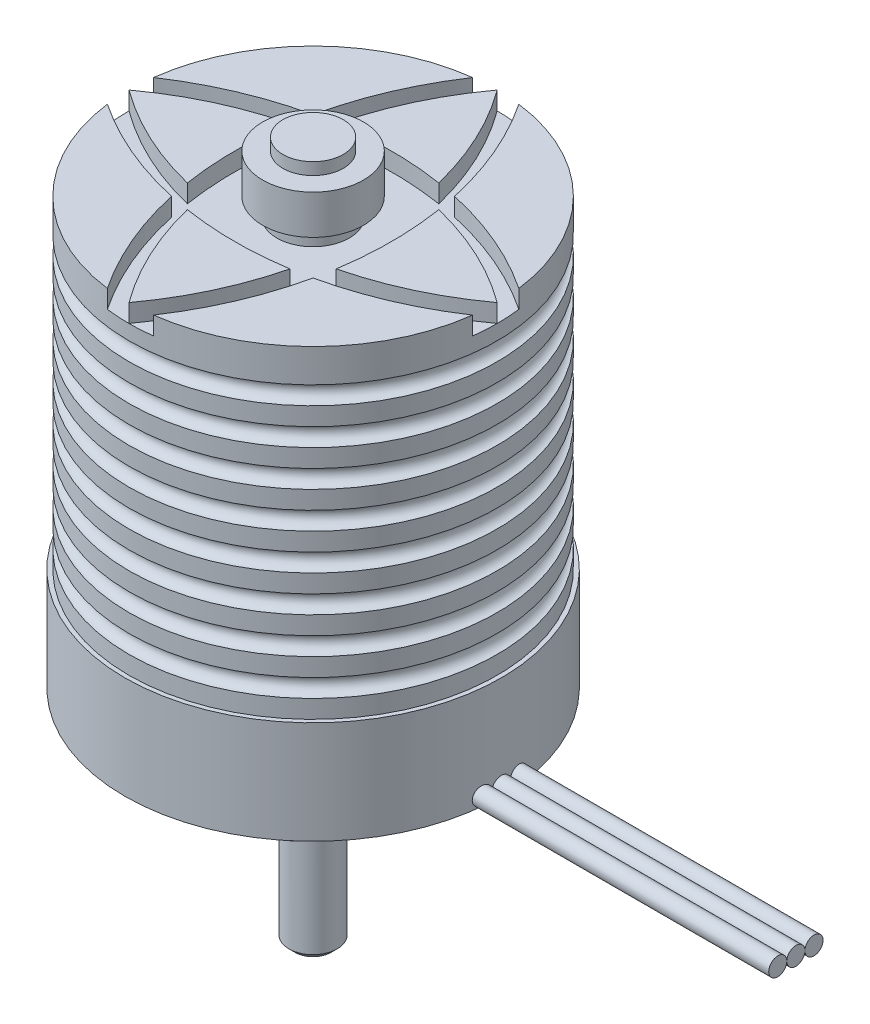
from build123d import *

# Parameters (mm, degrees)
SKETCH1_R                            = 30.5
BOSS_EXTRUDE1_DEPTH                  = 53.5
SKETCH3_R                            = 31.2
BOSS_EXTRUDE3_DEPTH                  = 17
BOSS_EXTRUDE2_START                  = 53.5
SKETCH2_R                            = 4
BOSS_EXTRUDE2_DEPTH                  = 107
LPATTERN3_COUNT                      = 8
LPATTERN3_PITCH                      = 6
SKETCH6_W                            = 1.65
SKETCH6_H                            = 17
TAP_DRILL_FOR_M4X0_7_TAP1_AT_2_COUNT = 2
TAP_DRILL_FOR_M4X0_7_TAP1_AT_2_PITCH = 44
TAP_DRILL_FOR_M4X0_7_TAP1_AT_3_COUNT = 2
TAP_DRILL_FOR_M4X0_7_TAP1_AT_3_PITCH = 31.112698372
TAP_DRILL_FOR_M4X0_7_TAP1_AT_4_COUNT = 2
TAP_DRILL_FOR_M4X0_7_TAP1_AT_4_PITCH = 31.112698372
CIRPATTERN1_COUNT                    = 2
CIRPATTERN1_ANGLE                    = 15
CIRPATTERN1_COPY_1_SKETCH_W          = 1.65
CIRPATTERN1_COPY_1_SKETCH_H          = 17
CIRPATTERN1_COPY_2_SKETCH_W          = 1.65
CIRPATTERN1_COPY_2_SKETCH_H          = 17
CIRPATTERN1_COPY_3_SKETCH_W          = 1.65
CIRPATTERN1_COPY_3_SKETCH_H          = 17
SKETCH7_R                            = 4
CUT_EXTRUDE1_DEPTH                   = 116.74057197
CUT_EXTRUDE_THIN1_START              = -3
CUT_EXTRUDE_THIN1_DEPTH              = 119.74057197
CIRPATTERN2_COUNT                    = 4
SKETCH9_R                            = 6
CUT_EXTRUDE2_DEPTH                   = 3
CUT_EXTRUDE3_DEPTH                   = 1.5
BOSS_EXTRUDE5_REACH                  = 151.348
BOSS_EXTRUDE5_END_RADIUS             = 31.2
BOSS_EXTRUDE5_START                  = 80
SKETCH11_R                           = 1.5
CHAMFER1_SIZE                        = 1


with BuildPart() as part:
    # Sketch1 → Boss-Extrude1 (new body)
    with BuildSketch(Plane(origin=(0, 0, 0), x_dir=(1, 0, 0), z_dir=(0, 1, 0))):
        with Locations(Location((0, 0, 0), (0, 0, 270))):
            Circle(SKETCH1_R)
    extrude(amount=BOSS_EXTRUDE1_DEPTH)

    # Sketch4 → Cut-Revolve1 (revolve, cut)
    with BuildSketch(Plane.XY, mode=Mode.PRIVATE) as cut_revolve1_sk:
        with BuildLine():
            Line((30.5, 6), (30.5, 3))
            ThreePointArc((30.5, 3), (29, 4.5), (30.5, 6))
        make_face()
    cut_revolve1 = revolve(cut_revolve1_sk.sketch.rotate(Axis((0, 0, 0), (0, 1, 0)), 90), axis=Axis((0, 0, 0), (0, 1, 0)), mode=Mode.SUBTRACT)

    # LPattern3: Cut-Revolve1 ×8
    with Locations(*[(0, i * LPATTERN3_PITCH, 0) for i in range(1, LPATTERN3_COUNT)]):
        add(cut_revolve1, mode=Mode.SUBTRACT)


with BuildPart() as body_2:
    # Sketch3 → Boss-Extrude3 (new body)
    with BuildSketch(Plane.XZ):
        with Locations(Location((0, 0, 0), (0, 0, 90))):
            Circle(SKETCH3_R)
    extrude(amount=BOSS_EXTRUDE3_DEPTH)

    # Sketch6 → Tap Drill for M4x0.7 Tap1 (revolve, cut)
    with BuildSketch(Plane(origin=(15.556349186, -17, 15.556349186), x_dir=(0, 0, -1), z_dir=(1, 0, 0))):
        with Locations((0.825, 8.5)):
            Rectangle(SKETCH6_W, SKETCH6_H)
    tap_drill_for_m4x0_7_tap1 = revolve(axis=Axis((15.556349186, -23.35, 15.556349186), (0, 1, 0)), mode=Mode.SUBTRACT)

    # Tap Drill for M4x0.7 Tap1 at 2: Tap Drill for M4x0.7 Tap1 ×2
    with Locations(*[Vector(-0.7071067811865474, 0, -0.7071067811865477) * (i * TAP_DRILL_FOR_M4X0_7_TAP1_AT_2_PITCH) for i in range(1, TAP_DRILL_FOR_M4X0_7_TAP1_AT_2_COUNT)]):
        add(tap_drill_for_m4x0_7_tap1, mode=Mode.SUBTRACT)

    # Tap Drill for M4x0.7 Tap1 at 3: Tap Drill for M4x0.7 Tap1 ×2
    with Locations(*[(-i * TAP_DRILL_FOR_M4X0_7_TAP1_AT_3_PITCH, 0, 0) for i in range(1, TAP_DRILL_FOR_M4X0_7_TAP1_AT_3_COUNT)]):
        add(tap_drill_for_m4x0_7_tap1, mode=Mode.SUBTRACT)

    # Tap Drill for M4x0.7 Tap1 at 4: Tap Drill for M4x0.7 Tap1 ×2
    with Locations(*[(0, 0, -i * TAP_DRILL_FOR_M4X0_7_TAP1_AT_4_PITCH) for i in range(1, TAP_DRILL_FOR_M4X0_7_TAP1_AT_4_COUNT)]):
        add(tap_drill_for_m4x0_7_tap1, mode=Mode.SUBTRACT)

    # CirPattern1: Tap Drill for M4x0.7 Tap1 ×2 about axis
    cirpattern1_axis = Axis((0, 0, 0), (0, 1, 0))
    for i in range(1, CIRPATTERN1_COUNT):
        add(tap_drill_for_m4x0_7_tap1.rotate(cirpattern1_axis, i * CIRPATTERN1_ANGLE / (CIRPATTERN1_COUNT - 1)), mode=Mode.SUBTRACT)

    # CirPattern1 copy 1 sketch → CirPattern1 copy 1 (revolve, cut)
    with BuildSketch(Plane(origin=(-19.052558883, -17, -11), x_dir=(-0.2588190451025214, 0, -0.9659258262890681), z_dir=(0.9659258262890681, 0, -0.2588190451025214))):
        with Locations((0.825, 8.5)):
            Rectangle(CIRPATTERN1_COPY_1_SKETCH_W, CIRPATTERN1_COPY_1_SKETCH_H)
    revolve(axis=Axis((-19.052558883, -23.35, -11), (0, 1, 0)), mode=Mode.SUBTRACT)

    # CirPattern1 copy 2 sketch → CirPattern1 copy 2 (revolve, cut)
    with BuildSketch(Plane(origin=(-11, -17, 19.052558883), x_dir=(-0.2588190451025214, 0, -0.9659258262890681), z_dir=(0.9659258262890681, 0, -0.2588190451025214))):
        with Locations((0.825, 8.5)):
            Rectangle(CIRPATTERN1_COPY_2_SKETCH_W, CIRPATTERN1_COPY_2_SKETCH_H)
    revolve(axis=Axis((-11, -23.35, 19.052558883), (0, 1, 0)), mode=Mode.SUBTRACT)

    # CirPattern1 copy 3 sketch → CirPattern1 copy 3 (revolve, cut)
    with BuildSketch(Plane(origin=(11, -17, -19.052558883), x_dir=(-0.2588190451025214, 0, -0.9659258262890681), z_dir=(0.9659258262890681, 0, -0.2588190451025214))):
        with Locations((0.825, 8.5)):
            Rectangle(CIRPATTERN1_COPY_3_SKETCH_W, CIRPATTERN1_COPY_3_SKETCH_H)
    revolve(axis=Axis((11, -23.35, -19.052558883), (0, 1, 0)), mode=Mode.SUBTRACT)


with BuildPart() as body_3:
    # Sketch2 → Boss-Extrude2 (new body)
    with BuildSketch(Plane(origin=(0, 0, 0), x_dir=(1, 0, 0), z_dir=(0, 1, 0)).offset(BOSS_EXTRUDE2_START)):
        with Locations(Location((0, 0, 0), (0, 0, 270))):
            Circle(SKETCH2_R)
    extrude(amount=-BOSS_EXTRUDE2_DEPTH)

    # Sketch10 → Cut-Extrude3 (cut)
    with BuildSketch(Plane.XY.offset(4)):
        with BuildLine():
            Line((1.415, -30.315), (1.415, -35.485))
            ThreePointArc((1.415, -35.485), (0, -36.9), (-1.415, -35.485))
            Line((-1.415, -35.485), (-1.415, -30.315))
            ThreePointArc((-1.415, -30.315), (0, -28.9), (1.415, -30.315))
        make_face()
    extrude(amount=-CUT_EXTRUDE3_DEPTH, mode=Mode.SUBTRACT)

    # Chamfer1
    chamfer1_edges = [body_3.edges().sort_by_distance(p)[0] for p in [
        (0, -53.5, -4),
    ]]
    chamfer(chamfer1_edges, length=CHAMFER1_SIZE)


with BuildPart() as cut_extrude1_tool:
    # Sketch7 → Cut-Extrude1 (new, through all)
    with BuildSketch(Plane.XZ.offset(53.5)):
        with Locations(Location((0, 0, 0), (0, 0, 90))):
            Circle(SKETCH7_R)
    extrude(amount=-CUT_EXTRUDE1_DEPTH)


with BuildPart() as body_2_1:
    add(body_2.part)

    # Cut-Extrude1: cut by cut_extrude1_tool
    add(cut_extrude1_tool.part, mode=Mode.SUBTRACT)


with BuildPart() as part_1:
    add(part.part)

    # Cut-Extrude1: cut by cut_extrude1_tool
    add(cut_extrude1_tool.part, mode=Mode.SUBTRACT)

    # Sketch8 → Cut-Extrude-Thin1 (cut)
    with BuildSketch(Plane(origin=(0, 53.5, 0), x_dir=(1, 0, 0), z_dir=(0, 1, 0)).offset(CUT_EXTRUDE_THIN1_START)):
        with BuildLine():
            ThreePointArc((0, -30.5), (-10, 0), (0, 30.5))
            Line((0, 30.5), (-2.417617083, 32.276267896))
            ThreePointArc((-2.417617083, 32.276267896), (-13, 0), (-2.417617083, -32.276267896))
            Line((-2.417617083, -32.276267896), (0, -30.5))
        make_face()
    cut_extrude_thin1 = extrude(amount=CUT_EXTRUDE_THIN1_DEPTH, mode=Mode.SUBTRACT)

    # CirPattern2: Cut-Extrude-Thin1 ×4 about axis
    cirpattern2_axis = Axis((0, 0, 0), (0, 1, 0))
    for i in range(1, CIRPATTERN2_COUNT):
        add(cut_extrude_thin1.rotate(cirpattern2_axis, i * 360 / CIRPATTERN2_COUNT), mode=Mode.SUBTRACT)

    # Sketch9 → Cut-Extrude2 (cut)
    with BuildSketch(Plane(origin=(0, 53.5, 0), x_dir=(1, 0, 0), z_dir=(0, 1, 0))):
        with BuildLine():
            ThreePointArc((9.176122343, -9.176122343), (10, 0), (9.176122343, 9.176122343))
            ThreePointArc((9.176122343, 9.176122343), (0, 10), (-9.176122343, 9.176122343))
            ThreePointArc((-9.176122343, 9.176122343), (-10, 0), (-9.176122343, -9.176122343))
            ThreePointArc((-9.176122343, -9.176122343), (0, -10), (9.176122343, -9.176122343))
        make_face()
        with Locations(Location((0, 0, 0), (0, 0, 270))):
            Circle(SKETCH9_R, mode=Mode.SUBTRACT)
    extrude(amount=-CUT_EXTRUDE2_DEPTH, mode=Mode.SUBTRACT)


with BuildPart() as body_4:
    # Boss-Extrude5: up to this cylinder (the profile starts outside it)
    boss_extrude5_end = Plane(origin=(0, -15.5, 0), z_dir=(0, 1, 0)) * Cylinder(BOSS_EXTRUDE5_END_RADIUS, 366.096, mode=Mode.PRIVATE)
    # Sketch11 → Boss-Extrude5 (new, up to the surface)
    with BuildSketch(Plane(origin=(0, 0, 0), x_dir=(0, 0, -1), z_dir=(1, 0, 0)).offset(BOSS_EXTRUDE5_START), mode=Mode.PRIVATE) as boss_extrude5_sk1:
        with Locations((-3, -15.5)):
            Circle(SKETCH11_R)
    boss_extrude5_tool1 = extrude(boss_extrude5_sk1.sketch, amount=-BOSS_EXTRUDE5_REACH, mode=Mode.PRIVATE) - boss_extrude5_end
    add(boss_extrude5_tool1.solids().sort_by_distance((80, -15.5, 3))[0])
    # Sketch11 → Boss-Extrude5 (new, up to the surface)
    with BuildSketch(Plane(origin=(0, 0, 0), x_dir=(0, 0, -1), z_dir=(1, 0, 0)).offset(BOSS_EXTRUDE5_START), mode=Mode.PRIVATE) as boss_extrude5_sk2:
        with Locations((0, -15.5)):
            Circle(SKETCH11_R)
    boss_extrude5_tool2 = extrude(boss_extrude5_sk2.sketch, amount=-BOSS_EXTRUDE5_REACH, mode=Mode.PRIVATE) - boss_extrude5_end
    add(boss_extrude5_tool2.solids().sort_by_distance((80, -15.5, 0))[0])
    # Sketch11 → Boss-Extrude5 (new, up to the surface)
    with BuildSketch(Plane(origin=(0, 0, 0), x_dir=(0, 0, -1), z_dir=(1, 0, 0)).offset(BOSS_EXTRUDE5_START), mode=Mode.PRIVATE) as boss_extrude5_sk3:
        with Locations((3, -15.5)):
            Circle(SKETCH11_R)
    boss_extrude5_tool3 = extrude(boss_extrude5_sk3.sketch, amount=-BOSS_EXTRUDE5_REACH, mode=Mode.PRIVATE) - boss_extrude5_end
    add(boss_extrude5_tool3.solids().sort_by_distance((80, -15.5, -3))[0])


with BuildPart() as body_5:
    # Sketch12 → Revolve1 (revolve)
    with BuildSketch(Plane.XY, mode=Mode.PRIVATE) as revolve1_sk:
        Polygon((0, 62), (-5, 62), (-5, 60), (-8.35, 60), (-8.35, 53.5), (0, 53.5), align=None)
    revolve(revolve1_sk.sketch.rotate(Axis((0, 62, 0), (0, -1, 0)), 90), axis=Axis((0, 62, 0), (0, -1, 0)))


solid = Compound([body_3.part, body_2_1.part, part_1.part, body_4.part, body_5.part])
